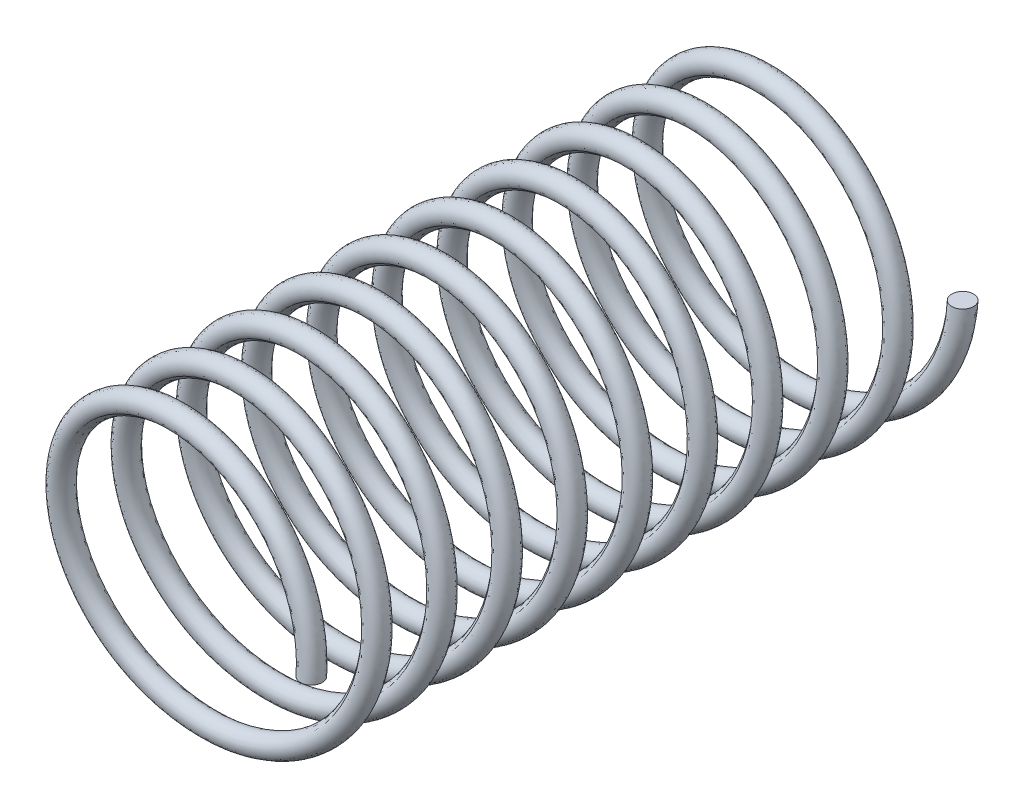
from build123d import *

# Parameters (mm, degrees)
AUSTRAGUNG1_PITCH  = 1.5
AUSTRAGUNG1_HEIGHT = 15
AUSTRAGUNG1_RADIUS = 3.25
SKIZZE2_R          = 0.25


with BuildPart() as part:
    # Austragung1: sweep along a helix
    with BuildLine() as austragung1_path:
        Helix(AUSTRAGUNG1_PITCH, AUSTRAGUNG1_HEIGHT, AUSTRAGUNG1_RADIUS, center=(0, 0, 0), direction=(0, 0, 1), lefthand=True)
    # Skizze2 → Austragung1 (sweep)
    with BuildSketch(Plane(origin=(0, 0, 0), x_dir=(0, 0, -1), z_dir=(1, 0, 0))):
        with Locations((0, -3.25)):
            Circle(SKIZZE2_R)
    sweep(path=austragung1_path.line, is_frenet=True)


solid = part.part
